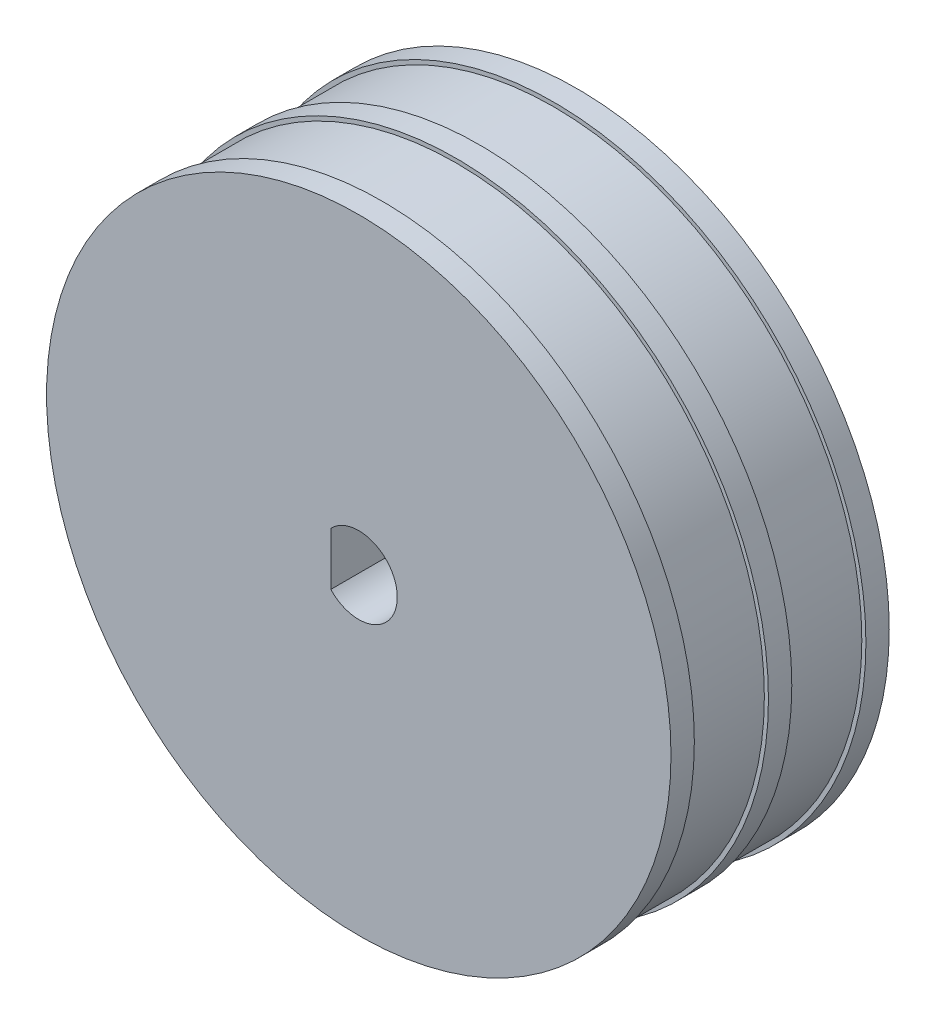
from build123d import *

# Parameters (mm, degrees)
SKETCH2_R           = 13.375
BOSS_EXTRUDE1_DEPTH = 1
SKETCH3_R           = 13.2
BOSS_EXTRUDE2_DEPTH = 3.175
SKETCH4_R           = 13.375
BOSS_EXTRUDE3_DEPTH = 1
SKETCH5_R           = 13.2
BOSS_EXTRUDE4_DEPTH = 3.175
SKETCH6_R           = 13.375
BOSS_EXTRUDE5_DEPTH = 1
CUT_EXTRUDE2_DEPTH  = 10.35


with BuildPart() as part:
    # Sketch2 → Boss-Extrude1 (new body)
    with BuildSketch(Plane.XY):
        Circle(SKETCH2_R)
    extrude(amount=BOSS_EXTRUDE1_DEPTH)

    # Sketch3 → Boss-Extrude2 (add)
    with BuildSketch(Plane.XY.offset(1)):
        Circle(SKETCH3_R)
    extrude(amount=BOSS_EXTRUDE2_DEPTH)

    # Sketch4 → Boss-Extrude3 (add)
    with BuildSketch(Plane.XY.offset(4.175)):
        Circle(SKETCH4_R)
    extrude(amount=BOSS_EXTRUDE3_DEPTH)

    # Sketch5 → Boss-Extrude4 (add)
    with BuildSketch(Plane.XY.offset(5.175)):
        Circle(SKETCH5_R)
    extrude(amount=BOSS_EXTRUDE4_DEPTH)

    # Sketch6 → Boss-Extrude5 (add)
    with BuildSketch(Plane.XY.offset(8.35)):
        Circle(SKETCH6_R)
    extrude(amount=BOSS_EXTRUDE5_DEPTH)

    # Sketch8 → Cut-Extrude2 (cut, through all)
    with BuildSketch(Plane(origin=(0, 0, 0), x_dir=(-1, 0, 0), z_dir=(0, 0, -1))):
        with BuildLine():
            Line((1.2, 1.132475165), (1.2, -1.132475165))
            ThreePointArc((1.2, -1.132475165), (-1.65, 0), (1.2, 1.132475165))
        make_face()
    extrude(amount=-CUT_EXTRUDE2_DEPTH, mode=Mode.SUBTRACT)


solid = part.part
